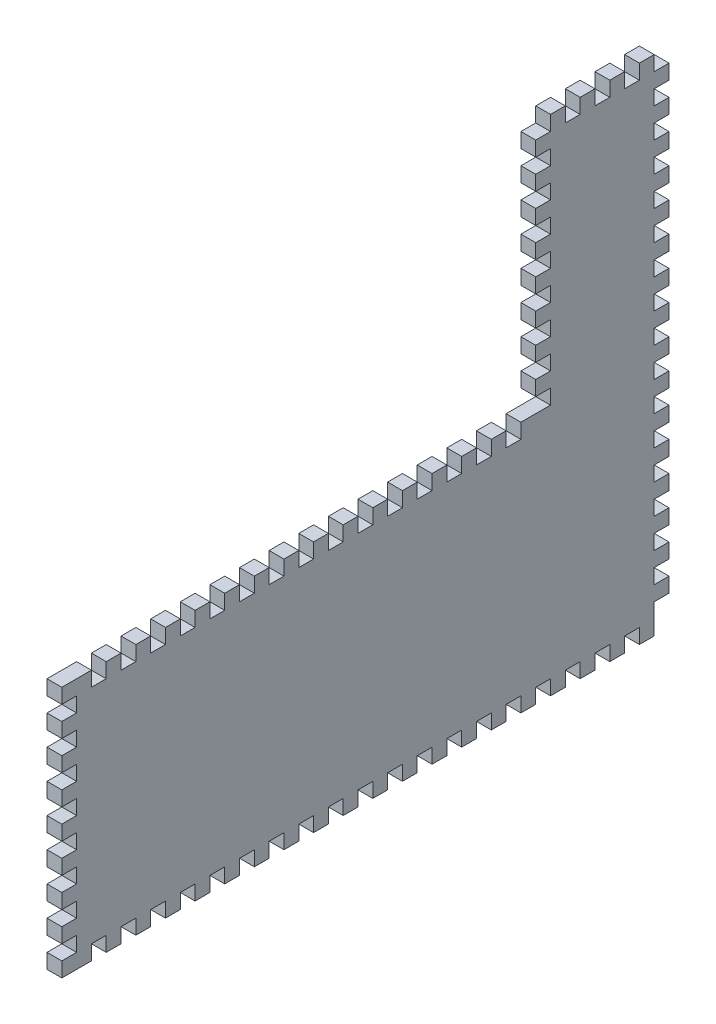
from build123d import *

# Parameters (mm, degrees)
BOSS_EXTRUDE1_DEPTH = 6.35
SKETCH2_W           = 6.35
SKETCH2_H           = 6.35
CUT_EXTRUDE1_DEPTH  = 7.35
LPATTERN1_COUNT     = 8
LPATTERN1_PITCH     = 12.7
SKETCH3_W           = 6.35
SKETCH3_H           = 6.35
CUT_EXTRUDE2_DEPTH  = 6.35
LPATTERN2_COUNT     = 20
LPATTERN2_PITCH     = 12.7
SKETCH4_W           = 6.35
SKETCH4_H           = 6.35
CUT_EXTRUDE3_DEPTH  = 7.35
LPATTERN3_COUNT     = 15
LPATTERN3_PITCH     = 12.7
SKETCH5_W           = 6.35
SKETCH5_H           = 6.35
CUT_EXTRUDE4_DEPTH  = 7.35
LPATTERN4_COUNT     = 17
LPATTERN4_PITCH     = 12.7
SKETCH6_W           = 6.35
SKETCH6_H           = 6.35
CUT_EXTRUDE5_DEPTH  = 7.35
LPATTERN5_COUNT     = 9
LPATTERN5_PITCH     = 12.7
LPATTERN6_COUNT     = 4
LPATTERN6_PITCH     = 12.7


with BuildPart() as part:
    # Sketch1 → Boss-Extrude1 (new body)
    with BuildSketch(Plane(origin=(0, 0, 0), x_dir=(0, 0, -1), z_dir=(1, 0, 0))):
        Polygon((-130.175, -53.975), (130.175, -53.975), (130.175, 53.975), (130.175, 161.925), (73.025, 161.925), (73.025, 53.975), (-130.175, 53.975), align=None)
    extrude(amount=BOSS_EXTRUDE1_DEPTH)

    # Sketch2 → Cut-Extrude1 (cut, through all)
    with BuildSketch(Plane(origin=(6.35, 0, 0), x_dir=(0, 0, -1), z_dir=(1, 0, 0))):
        with Locations((-127, -44.45)):
            Rectangle(SKETCH2_W, SKETCH2_H)
    cut_extrude1 = extrude(amount=-CUT_EXTRUDE1_DEPTH, mode=Mode.SUBTRACT)

    # LPattern1: Cut-Extrude1 ×8
    with Locations(*[(0, i * LPATTERN1_PITCH, 0) for i in range(1, LPATTERN1_COUNT)]):
        add(cut_extrude1, mode=Mode.SUBTRACT)

    # Sketch3 → Cut-Extrude2 (cut)
    with BuildSketch(Plane(origin=(6.35, 0, 0), x_dir=(0, 0, -1), z_dir=(1, 0, 0))):
        with Locations((-114.3, -50.8)):
            Rectangle(SKETCH3_W, SKETCH3_H)
    cut_extrude2 = extrude(amount=-CUT_EXTRUDE2_DEPTH, mode=Mode.SUBTRACT)

    # LPattern2: Cut-Extrude2 ×20
    with Locations(*[(0, 0, -i * LPATTERN2_PITCH) for i in range(1, LPATTERN2_COUNT)]):
        add(cut_extrude2, mode=Mode.SUBTRACT)

    # Sketch4 → Cut-Extrude3 (cut, through all)
    with BuildSketch(Plane(origin=(6.35, 0, 0), x_dir=(0, 0, -1), z_dir=(1, 0, 0))):
        with Locations((-114.3, 50.8)):
            Rectangle(SKETCH4_W, SKETCH4_H)
    cut_extrude3 = extrude(amount=-CUT_EXTRUDE3_DEPTH, mode=Mode.SUBTRACT)

    # LPattern3: Cut-Extrude3 ×15
    with Locations(*[(0, 0, -i * LPATTERN3_PITCH) for i in range(1, LPATTERN3_COUNT)]):
        add(cut_extrude3, mode=Mode.SUBTRACT)

    # Sketch5 → Cut-Extrude4 (cut, through all)
    with BuildSketch(Plane(origin=(6.35, 0, 0), x_dir=(0, 0, -1), z_dir=(1, 0, 0))):
        with Locations((127, 158.75)):
            Rectangle(SKETCH5_W, SKETCH5_H)
    cut_extrude4 = extrude(amount=-CUT_EXTRUDE4_DEPTH, mode=Mode.SUBTRACT)

    # LPattern4: Cut-Extrude4 ×17
    with Locations(*[(0, -i * LPATTERN4_PITCH, 0) for i in range(1, LPATTERN4_COUNT)]):
        add(cut_extrude4, mode=Mode.SUBTRACT)

    # Sketch6 → Cut-Extrude5 (cut, through all)
    with BuildSketch(Plane(origin=(6.35, 0, 0), x_dir=(0, 0, -1), z_dir=(1, 0, 0))):
        with Locations((76.2, 158.75)):
            Rectangle(SKETCH6_W, SKETCH6_H)
    cut_extrude5 = extrude(amount=-CUT_EXTRUDE5_DEPTH, mode=Mode.SUBTRACT)

    # LPattern5: Cut-Extrude5 ×9
    with Locations(*[(0, -i * LPATTERN5_PITCH, 0) for i in range(1, LPATTERN5_COUNT)]):
        add(cut_extrude5, mode=Mode.SUBTRACT)

    # LPattern6: Cut-Extrude5 ×4
    with Locations(*[(0, 0, -i * LPATTERN6_PITCH) for i in range(1, LPATTERN6_COUNT)]):
        add(cut_extrude5, mode=Mode.SUBTRACT)


solid = part.part
